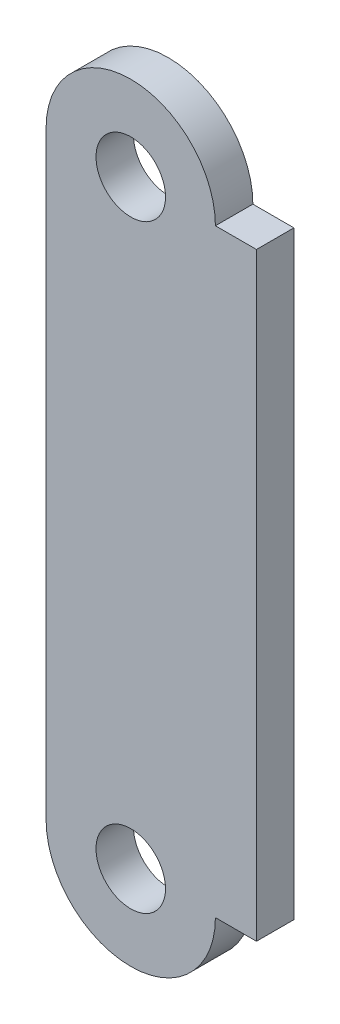
from build123d import *

# Parameters (mm, degrees)
BOSS_EXTRUDE1_DEPTH       = 1.5875
F_4_CLEARANCE_HOLE1_D     = 2.9464
F_4_CLEARANCE_HOLE1_DEPTH = 3.302
F_4_CLEARANCE_HOLE1_TIP   = 0.885187864
SKETCH5_W                 = 1.7399
SKETCH5_H                 = 25.4
BOSS_EXTRUDE2_DEPTH       = 1.5875


with BuildPart() as part:
    # Sketch1 → Boss-Extrude1 (new body)
    with BuildSketch(Plane.XY):
        with BuildLine():
            Line((3.58902, 12.7), (3.58902, -12.7))
            ThreePointArc((3.58902, -12.7), (0, -16.28902), (-3.58902, -12.7))
            Line((-3.58902, -12.7), (-3.58902, 12.7))
            ThreePointArc((-3.58902, 12.7), (0, 16.28902), (3.58902, 12.7))
        make_face()
    extrude(amount=BOSS_EXTRUDE1_DEPTH)

    # #4 Clearance Hole1
    with Locations(Plane.XY.offset(1.5875)):
        with Locations((0, 12.7), (0, -12.7)):
            Hole(F_4_CLEARANCE_HOLE1_D / 2, depth=F_4_CLEARANCE_HOLE1_DEPTH)
            with Locations((0, 0, -(F_4_CLEARANCE_HOLE1_DEPTH + F_4_CLEARANCE_HOLE1_TIP / 2))):  # 118° drill point
                Cone(0, F_4_CLEARANCE_HOLE1_D / 2, F_4_CLEARANCE_HOLE1_TIP, mode=Mode.SUBTRACT)

    # Sketch5 → Boss-Extrude2 (add)
    with BuildSketch(Plane.XY.offset(1.5875)):
        with Locations((4.45897, 0)):
            Rectangle(SKETCH5_W, SKETCH5_H)
    extrude(amount=-BOSS_EXTRUDE2_DEPTH)


solid = part.part
